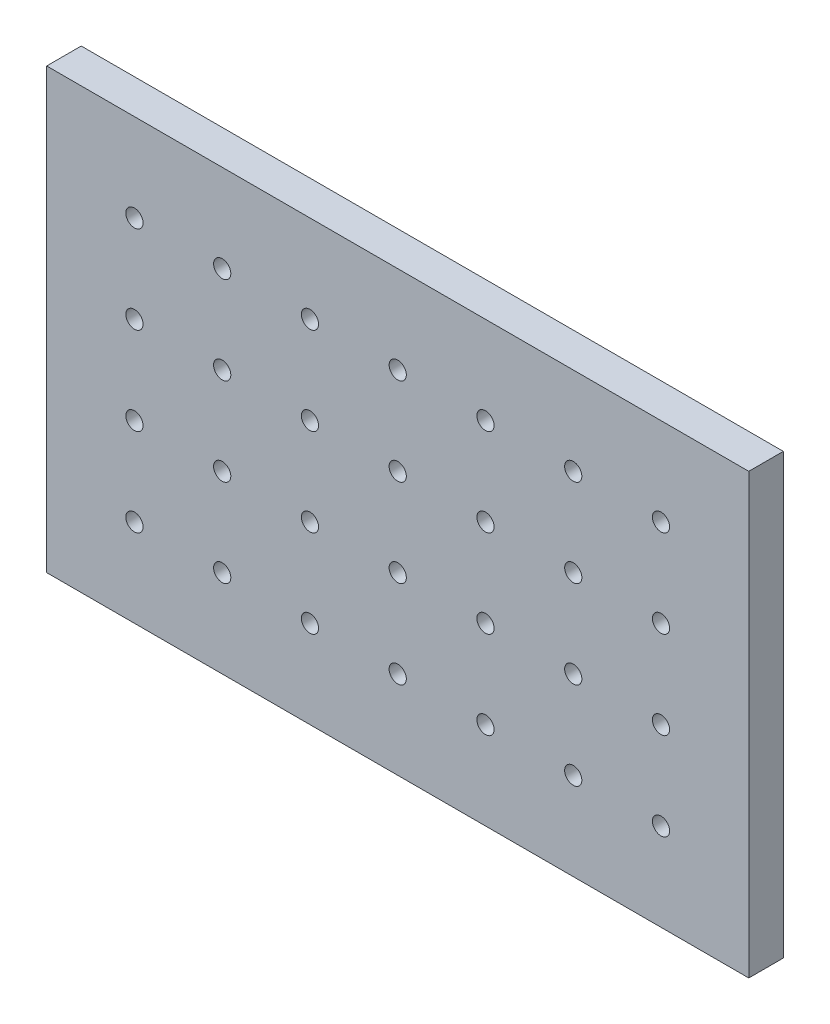
from build123d import *

# Parameters (mm, degrees)
SKETCH1_W           = 203.2
SKETCH1_H           = 127
BOSS_EXTRUDE1_DEPTH = 10
SKETCH2_R           = 2.49
CUT_EXTRUDE1_DEPTH  = 10


with BuildPart() as part:
    # Sketch1 → Boss-Extrude1 (new body)
    with BuildSketch(Plane.XY):
        with Locations((-101.6, -63.5)):
            Rectangle(SKETCH1_W, SKETCH1_H)
    extrude(amount=BOSS_EXTRUDE1_DEPTH)

    # Sketch2 → Cut-Extrude1 (cut)
    with BuildSketch(Plane.XY.offset(10)):
        with Locations((-177.8, -25.4)):
            Circle(SKETCH2_R)
        with Locations((-152.4, -25.4)):
            Circle(SKETCH2_R)
        with Locations((-127, -25.4)):
            Circle(SKETCH2_R)
        with Locations((-101.6, -25.4)):
            Circle(SKETCH2_R)
        with Locations((-76.2, -25.4)):
            Circle(SKETCH2_R)
        with Locations((-50.8, -25.4)):
            Circle(SKETCH2_R)
        with Locations((-25.4, -25.4)):
            Circle(SKETCH2_R)
        with Locations((-152.4, -50.8)):
            Circle(SKETCH2_R)
        with Locations((-127, -50.8)):
            Circle(SKETCH2_R)
        with Locations((-101.6, -50.8)):
            Circle(SKETCH2_R)
        with Locations((-76.2, -50.8)):
            Circle(SKETCH2_R)
        with Locations((-50.8, -50.8)):
            Circle(SKETCH2_R)
        with Locations((-25.4, -50.8)):
            Circle(SKETCH2_R)
        with Locations((-152.4, -76.2)):
            Circle(SKETCH2_R)
        with Locations((-127, -76.2)):
            Circle(SKETCH2_R)
        with Locations((-101.6, -76.2)):
            Circle(SKETCH2_R)
        with Locations((-76.2, -76.2)):
            Circle(SKETCH2_R)
        with Locations((-50.8, -76.2)):
            Circle(SKETCH2_R)
        with Locations((-25.4, -76.2)):
            Circle(SKETCH2_R)
        with Locations((-152.4, -101.6)):
            Circle(SKETCH2_R)
        with Locations((-127, -101.6)):
            Circle(SKETCH2_R)
        with Locations((-101.6, -101.6)):
            Circle(SKETCH2_R)
        with Locations((-76.2, -101.6)):
            Circle(SKETCH2_R)
        with Locations((-50.8, -101.6)):
            Circle(SKETCH2_R)
        with Locations((-25.4, -101.6)):
            Circle(SKETCH2_R)
        with Locations((-177.8, -50.8)):
            Circle(SKETCH2_R)
        with Locations((-177.8, -76.2)):
            Circle(SKETCH2_R)
        with Locations((-177.8, -101.6)):
            Circle(SKETCH2_R)
    extrude(amount=-CUT_EXTRUDE1_DEPTH, mode=Mode.SUBTRACT)


solid = part.part
